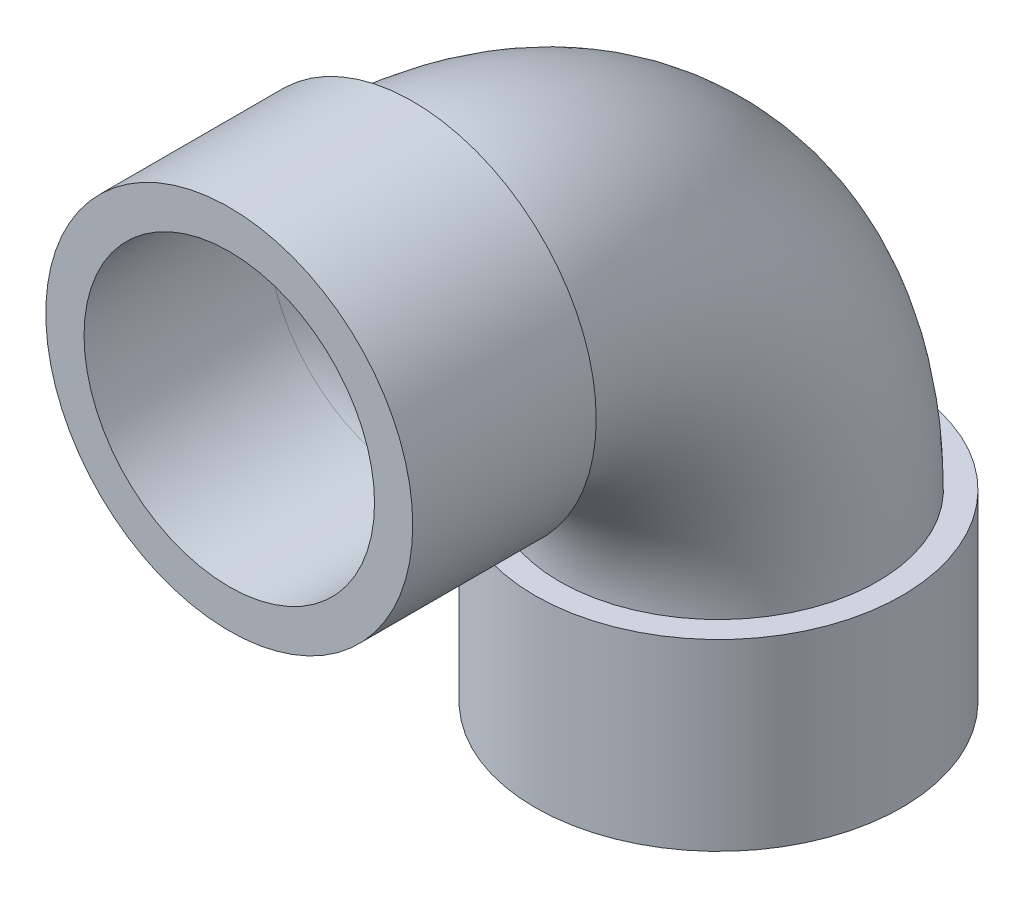
from build123d import *

# Parameters (mm, degrees)
SKETCH1_R           = 38.1
SKETCH1_R_2         = 30.1625
BOSS_EXTRUDE1_DEPTH = 38.1
SKETCH4_R           = 38.1
SKETCH4_R_2         = 30.1625
BOSS_EXTRUDE2_DEPTH = 38.1
SKETCH6_R           = 33.02
SKETCH6_R_2         = 30.1625


with BuildPart() as part:
    # Sketch1 → Boss-Extrude1 (new body)
    with BuildSketch(Plane(origin=(0, 0, 0), x_dir=(1, 0, 0), z_dir=(0, 1, 0))):
        Circle(SKETCH1_R)
        Circle(SKETCH1_R_2, mode=Mode.SUBTRACT)
    extrude(amount=BOSS_EXTRUDE1_DEPTH)



with BuildPart() as body_2:
    # Sketch4 → Boss-Extrude2 (new body)
    with BuildSketch(Plane.XY.offset(63.5)):
        with Locations((0, 101.6)):
            Circle(SKETCH4_R)
        with Locations((0, 101.6)):
            Circle(SKETCH4_R_2, mode=Mode.SUBTRACT)
    extrude(amount=BOSS_EXTRUDE2_DEPTH)


with BuildPart() as part_1:
    add(part.part)

    add(body_2.part)  # Sweep2 merges body 2
    # Sweep2: sweep along a path in Sketch3
    with BuildLine(Plane(origin=(0, 0, 0), x_dir=(0, 0, -1), z_dir=(1, 0, 0))) as sweep2_path:
        ThreePointArc((0, 38.1), (-18.598719395, 83.001280605), (-63.5, 101.6))
    # Sketch6 → Sweep2 (sweep)
    with BuildSketch(Plane(origin=(0, 38.1, 0), x_dir=(1, 0, 0), z_dir=(0, 1, 0))):
        Circle(SKETCH6_R)
        Circle(SKETCH6_R_2, mode=Mode.SUBTRACT)
    sweep(path=sweep2_path.line)


solid = part_1.part
